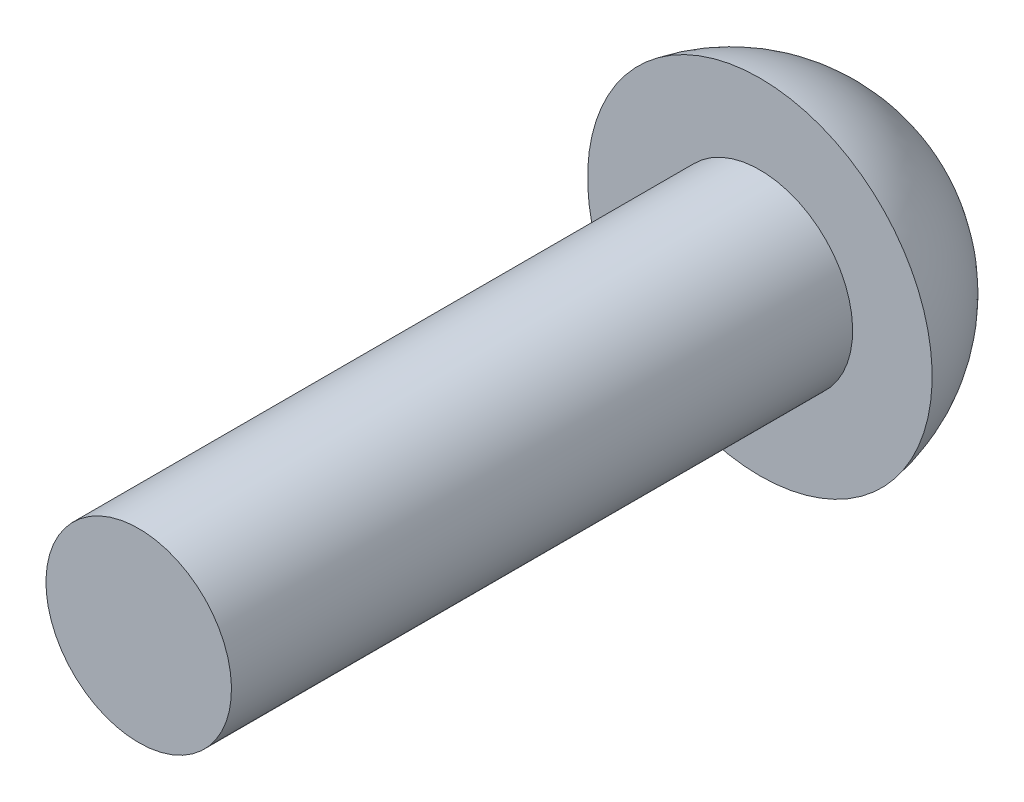
from build123d import *


with BuildPart() as part:
    # Sketch2 → Revolve1 (revolve)
    with BuildSketch(Plane(origin=(0, 0, 0), x_dir=(0, 0, -1), z_dir=(1, 0, 0))):
        with BuildLine():
            Line((0, 0), (0, 1.4224))
            Line((0, 1.4224), (9.525, 1.4224))
            Line((9.525, 1.4224), (9.525, 2.6416))
            ThreePointArc((9.525, 2.6416), (11.12641941, 1.730185655), (11.7602, 0))
            Line((11.7602, 0), (0, 0))
        make_face()
    revolve(axis=Axis((0, 0, 0), (0, 0, -1)))


solid = part.part
